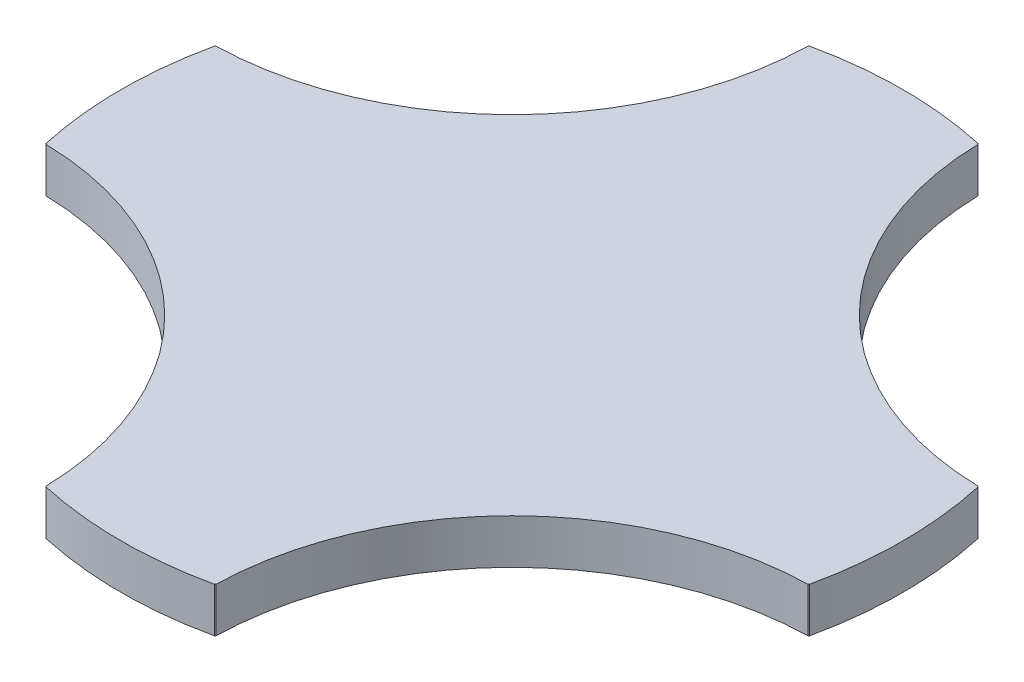
from build123d import *

# Parameters (mm, degrees)
BOSS_EXTRUDE1_DEPTH = 0.36


with BuildPart() as part:
    # Sketch1 → Boss-Extrude1 (new body)
    with BuildSketch(Plane(origin=(0, 0, 0), x_dir=(1, 0, 0), z_dir=(0, 1, 0))):
        with BuildLine():
            ThreePointArc((-3.076008358, 0.67872865), (-3.15, 0), (-3.076008358, -0.67872865))
            Line((-3.076008358, -0.67872865), (-3.069737008, -0.685))
            ThreePointArc((-3.069737008, -0.685), (-1.399047345, -1.399047345), (-0.685, -3.069737008))
            Line((-0.685, -3.069737008), (-0.67872865, -3.076008358))
            ThreePointArc((-0.67872865, -3.076008358), (0, -3.15), (0.67872865, -3.076008358))
            Line((0.67872865, -3.076008358), (0.685, -3.069737008))
            ThreePointArc((0.685, -3.069737008), (1.399047345, -1.399047345), (3.069737008, -0.685))
            Line((3.069737008, -0.685), (3.076008358, -0.67872865))
            ThreePointArc((3.076008358, -0.67872865), (3.15, 0), (3.076008358, 0.67872865))
            Line((3.076008358, 0.67872865), (3.069737008, 0.685))
            ThreePointArc((3.069737008, 0.685), (1.399047345, 1.399047345), (0.685, 3.069737008))
            Line((0.685, 3.069737008), (0.67872865, 3.076008358))
            ThreePointArc((0.67872865, 3.076008358), (0, 3.15), (-0.67872865, 3.076008358))
            Line((-0.67872865, 3.076008358), (-0.685, 3.069737008))
            ThreePointArc((-0.685, 3.069737008), (-1.399047345, 1.399047345), (-3.069737008, 0.685))
            Line((-3.069737008, 0.685), (-3.076008358, 0.67872865))
        make_face()
    extrude(amount=BOSS_EXTRUDE1_DEPTH)


solid = part.part
